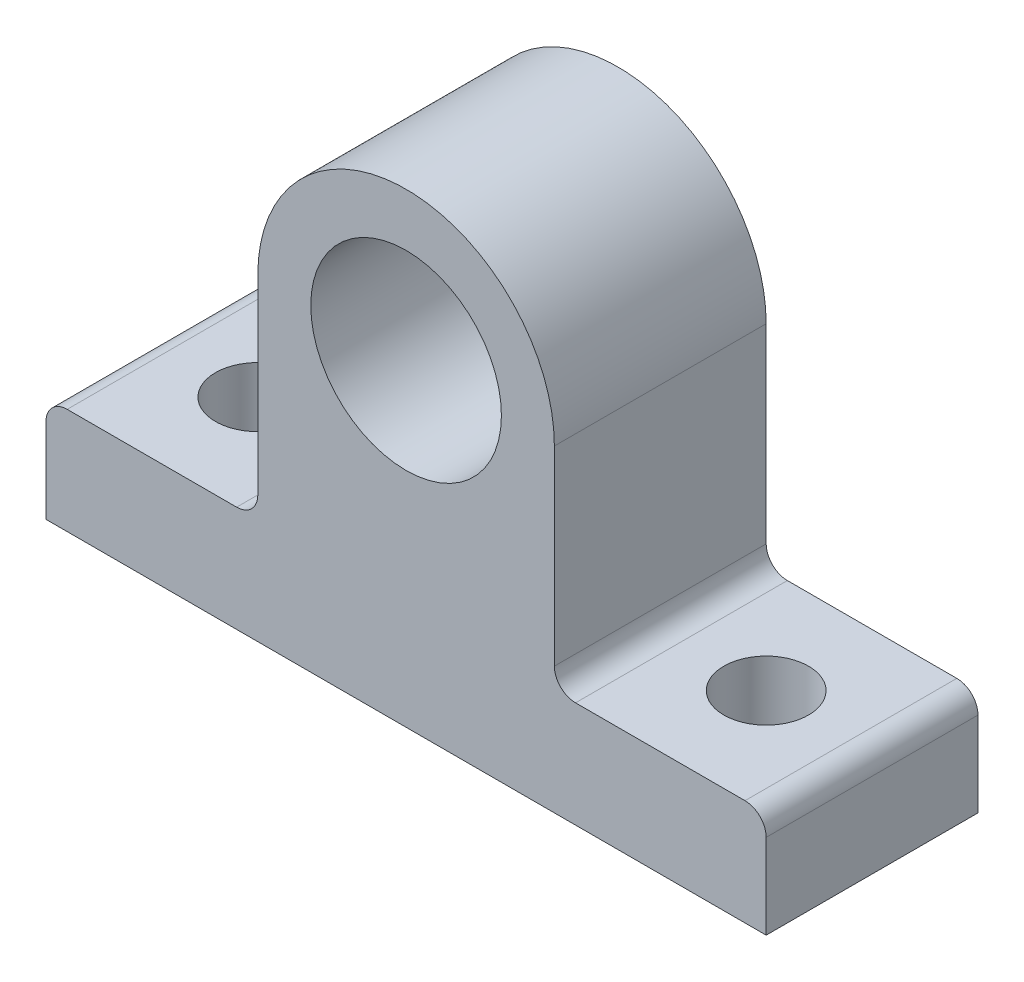
from build123d import *

# Parameters (mm, degrees)
SKETCH_1_R          = 4.5
EXTRUDE_1_DEPTH     = 10
CUT_EXTRUDE_1_REACH = 7
SKETCH_2_R          = 2
FILLET_2_R          = 1


with BuildPart() as part:
    # 草圖1 → 填料-伸長1 (new body)
    with BuildSketch(Plane.XY):
        with BuildLine():
            Line((7, -10), (7, 0))
            ThreePointArc((7, 0), (0, 7), (-7, 0))
            Line((-7, 0), (-7, -10))
            Line((-7, -10), (-17, -10))
            Line((-17, -10), (-17, -15))
            Line((-17, -15), (17, -15))
            Line((17, -15), (17, -10))
            Line((17, -10), (7, -10))
        make_face()
        Circle(SKETCH_1_R, mode=Mode.SUBTRACT)
    extrude(amount=EXTRUDE_1_DEPTH)

    # 草圖2 → 除料-伸長1 (cut, up to next)
    with BuildSketch(Plane(origin=(0, -10, 0), x_dir=(1, 0, 0), z_dir=(0, 1, 0)), mode=Mode.PRIVATE) as cut_extrude_1_sk1:
        with Locations((12, -5)):
            Circle(SKETCH_2_R)
    cut_extrude_1_tool1 = extrude(cut_extrude_1_sk1.sketch, amount=-CUT_EXTRUDE_1_REACH, mode=Mode.PRIVATE) & part.part
    add(cut_extrude_1_tool1.solids().sort_by_distance((12, -10, 5))[0], mode=Mode.SUBTRACT)
    # 草圖2 → 除料-伸長1 (cut, up to next)
    with BuildSketch(Plane(origin=(0, -10, 0), x_dir=(1, 0, 0), z_dir=(0, 1, 0)), mode=Mode.PRIVATE) as cut_extrude_1_sk2:
        with Locations((-12, -5)):
            Circle(SKETCH_2_R)
    cut_extrude_1_tool2 = extrude(cut_extrude_1_sk2.sketch, amount=-CUT_EXTRUDE_1_REACH, mode=Mode.PRIVATE) & part.part
    add(cut_extrude_1_tool2.solids().sort_by_distance((-12, -10, 5))[0], mode=Mode.SUBTRACT)

    # 圓角2
    fillet_2_edges = [part.edges().sort_by_distance(p)[0] for p in [
        (-17, -10, 5),
        (-7, -10, 5),
        (7, -10, 5),
        (17, -10, 5),
    ]]
    fillet(fillet_2_edges, radius=FILLET_2_R)


solid = part.part
